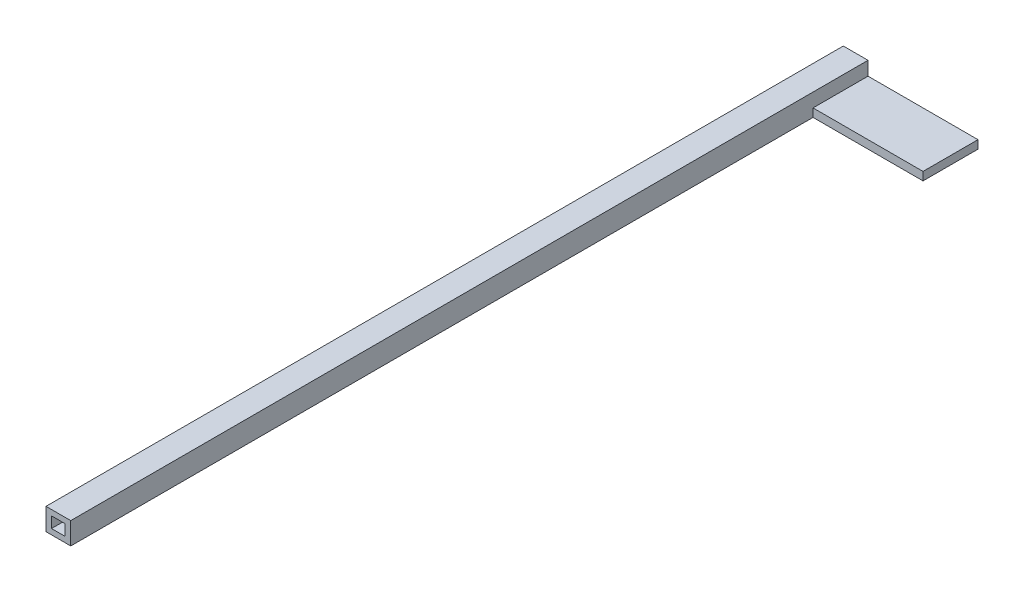
from build123d import *

# Parameters (mm, degrees)
SKETCH1_W           = 9
SKETCH1_H           = 8
BOSS_EXTRUDE1_DEPTH = 290
SKETCH2_W           = 20
SKETCH2_H           = 3
BOSS_EXTRUDE2_DEPTH = 40
SKETCH3_W           = 5
SKETCH3_H           = 4
CUT_EXTRUDE1_DEPTH  = 20


with BuildPart() as part:
    # Sketch1 → Boss-Extrude1 (new body)
    with BuildSketch(Plane.XY):
        Rectangle(SKETCH1_W, SKETCH1_H)
    extrude(amount=BOSS_EXTRUDE1_DEPTH)

    # Sketch2 → Boss-Extrude2 (add)
    with BuildSketch(Plane(origin=(4.5, 0, 0), x_dir=(0, 0, -1), z_dir=(1, 0, 0))):
        with Locations((-10, -2.5)):
            Rectangle(SKETCH2_W, SKETCH2_H)
    extrude(amount=BOSS_EXTRUDE2_DEPTH)

    # Sketch3 → Cut-Extrude1 (cut)
    with BuildSketch(Plane.XY.offset(290)):
        Rectangle(SKETCH3_W, SKETCH3_H)
    extrude(amount=-CUT_EXTRUDE1_DEPTH, mode=Mode.SUBTRACT)


solid = part.part
